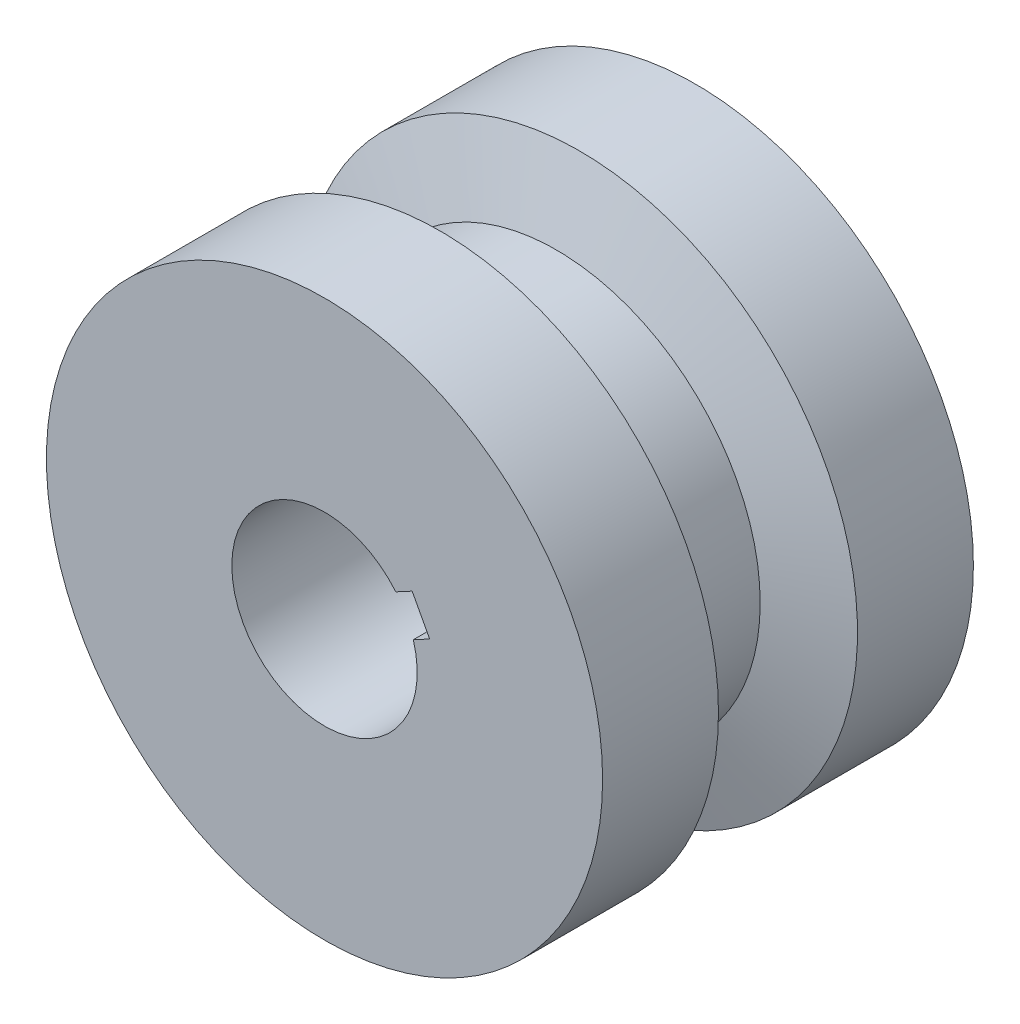
from build123d import *

# Parameters (mm, degrees)
SKETCH1_R           = 7.5
SKETCH1_R_2         = 2.5
BOSS_EXTRUDE1_DEPTH = 5
CUT_EXTRUDE1_DEPTH  = 10


with BuildPart() as part:
    # Sketch1 → Boss-Extrude1 (new body, symmetric)
    with BuildSketch(Plane.XY):
        Circle(SKETCH1_R)
        Circle(SKETCH1_R_2, mode=Mode.SUBTRACT)
    extrude(amount=BOSS_EXTRUDE1_DEPTH, both=True)

    # Sketch3 → Cut-Revolve1 (revolve, cut)
    with BuildSketch(Plane(origin=(0, 0, 0), x_dir=(0, 0, -1), z_dir=(1, 0, 0))):
        Polygon((-2.5, 9.5), (-1.25, 5.5), (1.25, 5.5), (2.5, 9.5), align=None)
    revolve(axis=Axis((0, 0, 9.747557678), (0, 0, -1)), mode=Mode.SUBTRACT)

    # Sketch4 → Cut-Extrude1 (cut)
    with BuildSketch(Plane(origin=(0, 0, -5), x_dir=(-1, 0, 0), z_dir=(0, 0, -1))):
        with BuildLine():
            Line((-2.395260625, 0.716049259), (-2.835991961, 0.952176109))
            Line((-2.835991961, 0.952176109), (-2.36373826, 1.833638781))
            Line((-2.36373826, 1.833638781), (-1.923006924, 1.597511931))
            ThreePointArc((-1.923006924, 1.597511931), (-2.203656681, 1.180634251), (-2.395260625, 0.716049259))
        make_face()
    extrude(amount=-CUT_EXTRUDE1_DEPTH, mode=Mode.SUBTRACT)


solid = part.part
